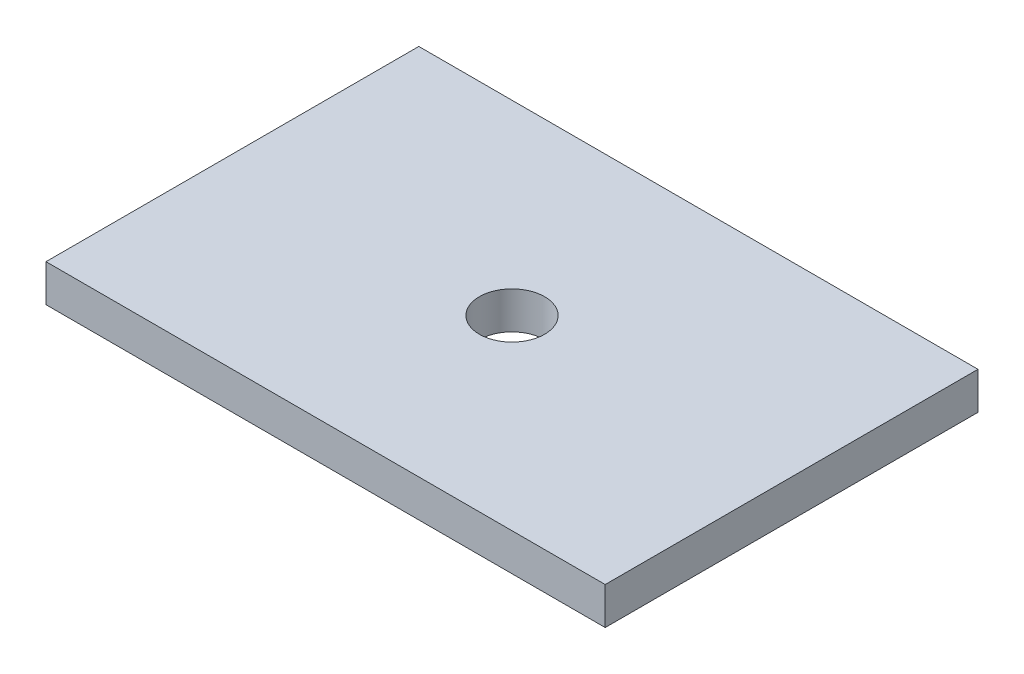
from build123d import *

# Parameters (mm, degrees)
SKETCH1_W           = 30
SKETCH1_H           = 20
BOSS_EXTRUDE1_DEPTH = 2
SKETCH2_R           = 1.75
CUT_EXTRUDE1_DEPTH  = 19.138357147


with BuildPart() as part:
    # Sketch1 → Boss-Extrude1 (new body)
    with BuildSketch(Plane(origin=(0, 0, 0), x_dir=(1, 0, 0), z_dir=(0, 1, 0))):
        Rectangle(SKETCH1_W, SKETCH1_H)
    extrude(amount=BOSS_EXTRUDE1_DEPTH)

    # Sketch2 → Cut-Extrude1 (cut, through all)
    with BuildSketch(Plane(origin=(0, 2, 0), x_dir=(1, 0, 0), z_dir=(0, 1, 0))):
        Circle(SKETCH2_R)
    extrude(amount=-CUT_EXTRUDE1_DEPTH, mode=Mode.SUBTRACT)


solid = part.part
